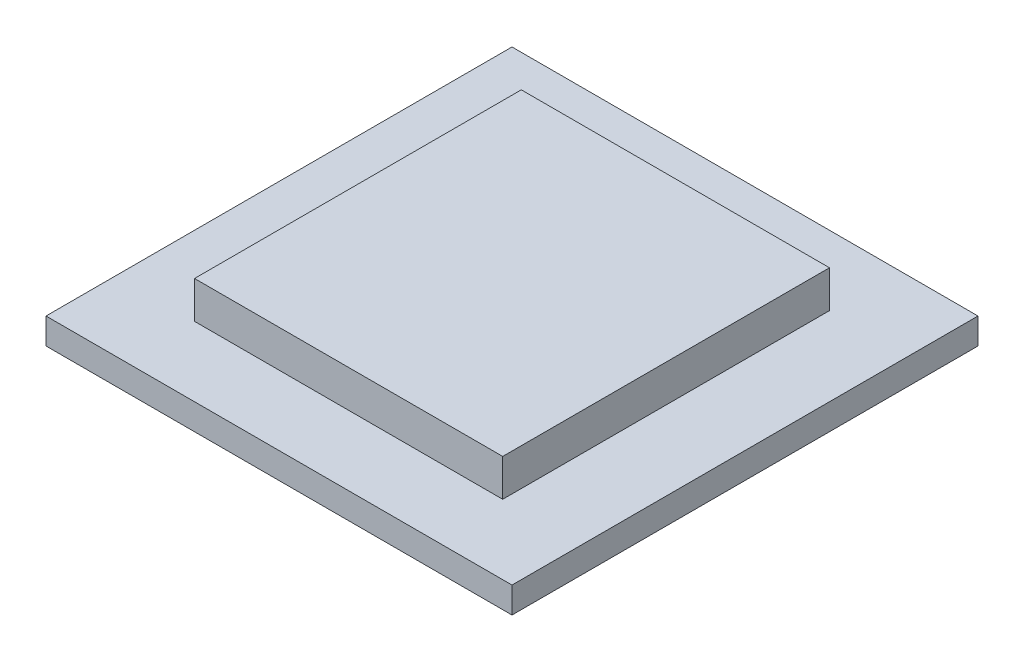
from build123d import *

# Parameters (mm, degrees)
SKETCH1_W           = 16.6
SKETCH1_H           = 17.6
BOSS_EXTRUDE1_DEPTH = 2
SKETCH1_4_W         = 25.1
SKETCH1_4_H         = 25.1
BOSS_EXTRUDE2_DEPTH = 1.4


with BuildPart() as part:
    # Sketch1 → Boss-Extrude1 (new body)
    with BuildSketch(Plane(origin=(0, 0, 0), x_dir=(1, 0, 0), z_dir=(0, 1, 0))):
        Rectangle(SKETCH1_W, SKETCH1_H)
    extrude(amount=BOSS_EXTRUDE1_DEPTH)

    # Sketch1_4 → Boss-Extrude2 (add)
    with BuildSketch(Plane(origin=(0, 0, 0), x_dir=(1, 0, 0), z_dir=(0, 1, 0))):
        Rectangle(SKETCH1_4_W, SKETCH1_4_H)
    extrude(amount=-BOSS_EXTRUDE2_DEPTH)


solid = part.part
